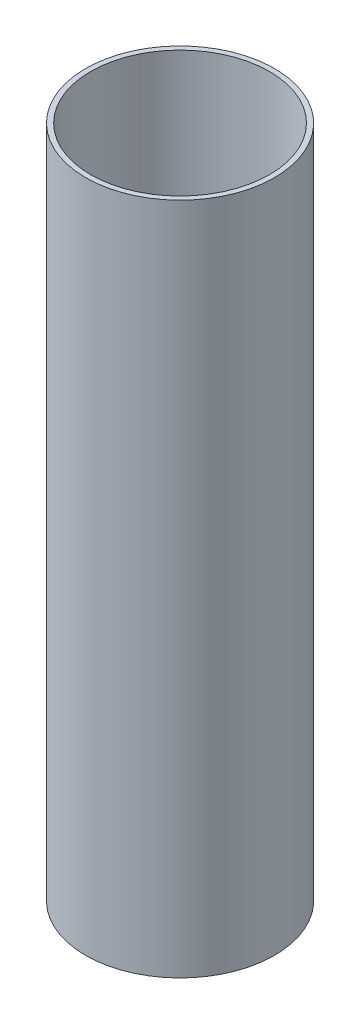
from build123d import *

# Parameters (mm, degrees)
SKETCH1_W = 1.524
SKETCH1_H = 203.2


with BuildPart() as part:
    # Sketch1 → Revolve1 (revolve)
    with BuildSketch(Plane.XY):
        with Locations((27.7368, 101.6)):
            Rectangle(SKETCH1_W, SKETCH1_H)
    revolve(axis=Axis((0, 307.012038368, 0), (0, -1, 0)))


solid = part.part
